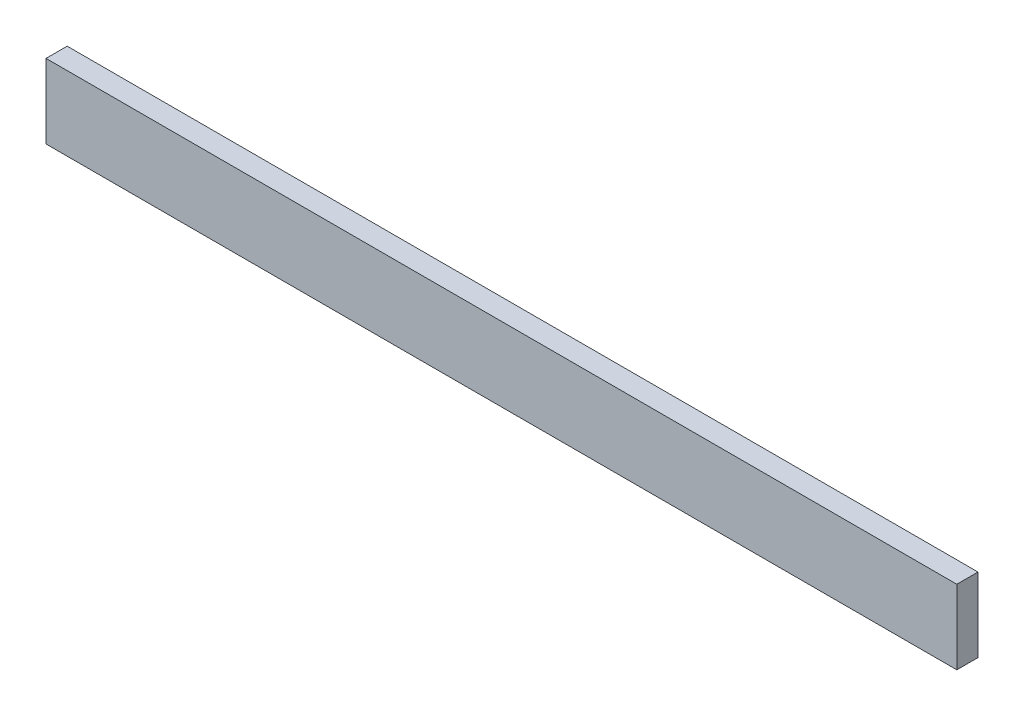
from build123d import *

# Parameters (mm, degrees)
SKETCH1_W           = 172
SKETCH1_H           = 14
BOSS_EXTRUDE1_DEPTH = 4


with BuildPart() as part:
    # Sketch1 → Boss-Extrude1 (new body)
    with BuildSketch(Plane.XY):
        Rectangle(SKETCH1_W, SKETCH1_H)
    extrude(amount=-BOSS_EXTRUDE1_DEPTH)


solid = part.part
